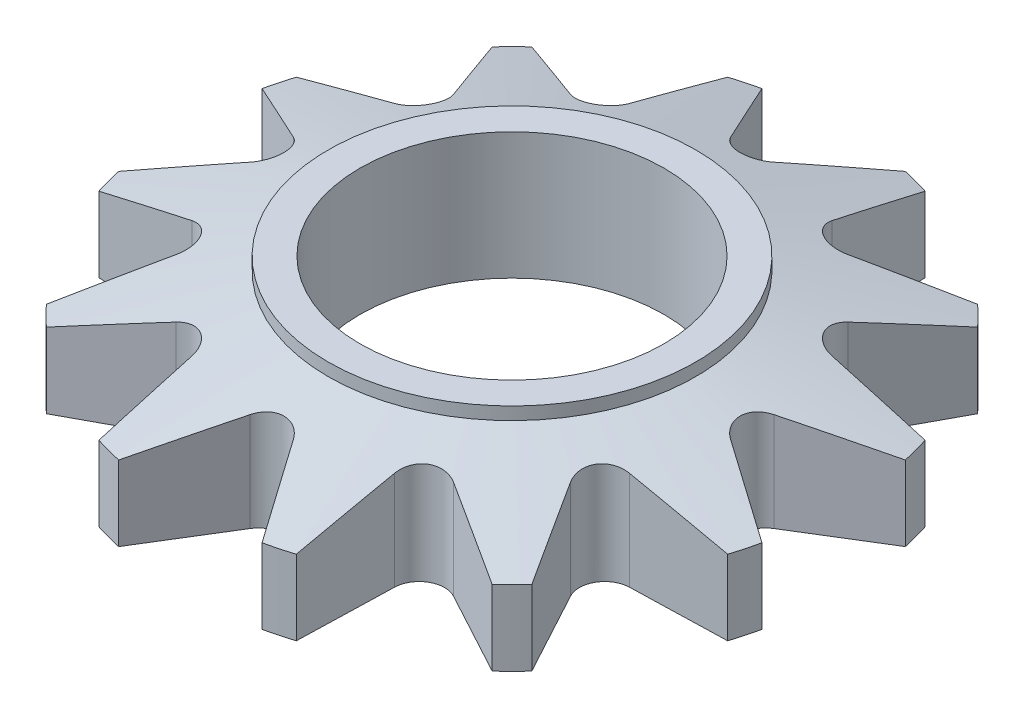
from build123d import *

# Parameters (mm, degrees)
SKETCH1_R               = 260
SKETCH1_R_2             = 120
BOSS_EXTRUDE1_DEPTH     = 45
SKETCH2_R               = 145
SKETCH2_R_2             = 120
BOSS_EXTRUDE3_DEPTH     = 55
CUT_EXTRUDE1_DEPTH      = 56
CUT_EXTRUDE1_DEPTH_BACK = 46
SCALE2_SCALE            = 0.4


with BuildPart() as part:
    # Sketch1 → Boss-Extrude1 (new body, symmetric)
    with BuildSketch(Plane(origin=(0, 0, 0), x_dir=(1, 0, 0), z_dir=(0, 1, 0))):
        Circle(SKETCH1_R)
        Circle(SKETCH1_R_2, mode=Mode.SUBTRACT)
    extrude(amount=BOSS_EXTRUDE1_DEPTH, both=True)

    # Sketch2 → Boss-Extrude3 (add)
    with BuildSketch(Plane(origin=(0, 0, 0), x_dir=(1, 0, 0), z_dir=(0, 1, 0))):
        Circle(SKETCH2_R)
        Circle(SKETCH2_R_2, mode=Mode.SUBTRACT)
    extrude(amount=BOSS_EXTRUDE3_DEPTH)

    # Sketch4 → Cut-Extrude1 (cut, two sides)
    with BuildSketch(Plane(origin=(0, 0, 0), x_dir=(1, 0, 0), z_dir=(0, 1, 0))) as cut_extrude1_sk:
        with BuildLine():
            Line((-17.033179487, 189.518072861), (-56.573051576, 253.770545642))
            ThreePointArc((-56.573051576, 253.770545642), (0, 260), (56.573051576, 253.770545642))
            Line((56.573051576, 253.770545642), (17.033179487, 189.518072861))
            ThreePointArc((17.033179487, 189.518072861), (0, 180), (-17.033179487, 189.518072861))
        make_face()
        with BuildLine():
            Line((109.510202574, 155.61087583), (175.878972656, 191.48521347))
            ThreePointArc((175.878972656, 191.48521347), (130, 225.166604984), (77.891572987, 248.058265046))
            Line((77.891572987, 248.058265046), (80.007870288, 172.644055317))
            ThreePointArc((80.007870288, 172.644055317), (90, 155.884572681), (109.510202574, 155.61087583))
        make_face()
        with BuildLine():
            Line((172.644055318, 80.007870287), (248.058265047, 77.891572986))
            ThreePointArc((248.058265047, 77.891572986), (225.166604985, 130), (191.485213471, 175.878972655))
            Line((191.485213471, 175.878972655), (155.610875831, 109.510202573))
            ThreePointArc((155.610875831, 109.510202573), (155.884572682, 90), (172.644055318, 80.007870287))
        make_face()
        with BuildLine():
            Line((189.518072862, -17.033179488), (253.770545643, -56.573051577))
            ThreePointArc((253.770545643, -56.573051577), (260.000000001, -1e-09), (253.770545643, 56.573051575))
            Line((253.770545643, 56.573051575), (189.518072862, 17.033179486))
            ThreePointArc((189.518072862, 17.033179486), (180.000000001, -1e-09), (189.518072862, -17.033179488))
        make_face()
        with BuildLine():
            Line((155.610875831, -109.510202575), (191.485213471, -175.878972657))
            ThreePointArc((191.485213471, -175.878972657), (225.166604985, -130.000000001), (248.058265047, -77.891572988))
            Line((248.058265047, -77.891572988), (172.644055318, -80.007870289))
            ThreePointArc((172.644055318, -80.007870289), (155.884572682, -90.000000001), (155.610875831, -109.510202575))
        make_face()
        with BuildLine():
            Line((80.007870288, -172.644055319), (77.891572987, -248.058265048))
            ThreePointArc((77.891572987, -248.058265048), (130, -225.166604986), (175.878972656, -191.485213472))
            Line((175.878972656, -191.485213472), (109.510202574, -155.610875832))
            ThreePointArc((109.510202574, -155.610875832), (90, -155.884572683), (80.007870288, -172.644055319))
        make_face()
        with BuildLine():
            Line((-17.033179487, -189.518072863), (-56.573051576, -253.770545644))
            ThreePointArc((-56.573051576, -253.770545644), (0, -260.000000002), (56.573051576, -253.770545644))
            Line((56.573051576, -253.770545644), (17.033179487, -189.518072863))
            ThreePointArc((17.033179487, -189.518072863), (0, -180.000000002), (-17.033179487, -189.518072863))
        make_face()
        with BuildLine():
            Line((-109.510202574, -155.610875832), (-175.878972656, -191.485213472))
            ThreePointArc((-175.878972656, -191.485213472), (-130, -225.166604986), (-77.891572987, -248.058265048))
            Line((-77.891572987, -248.058265048), (-80.007870288, -172.644055319))
            ThreePointArc((-80.007870288, -172.644055319), (-90, -155.884572683), (-109.510202574, -155.610875832))
        make_face()
        with BuildLine():
            Line((-172.644055318, -80.007870289), (-248.058265047, -77.891572988))
            ThreePointArc((-248.058265047, -77.891572988), (-225.166604985, -130.000000001), (-191.485213471, -175.878972657))
            Line((-191.485213471, -175.878972657), (-155.610875831, -109.510202575))
            ThreePointArc((-155.610875831, -109.510202575), (-155.884572682, -90.000000001), (-172.644055318, -80.007870289))
        make_face()
        with BuildLine():
            Line((-189.518072862, 17.033179486), (-253.770545643, 56.573051575))
            ThreePointArc((-253.770545643, 56.573051575), (-260.000000001, -1e-09), (-253.770545643, -56.573051577))
            Line((-253.770545643, -56.573051577), (-189.518072862, -17.033179488))
            ThreePointArc((-189.518072862, -17.033179488), (-180.000000001, -1e-09), (-189.518072862, 17.033179486))
        make_face()
        with BuildLine():
            Line((-155.610875831, 109.510202573), (-191.485213471, 175.878972655))
            ThreePointArc((-191.485213471, 175.878972655), (-225.166604985, 130), (-248.058265047, 77.891572986))
            Line((-248.058265047, 77.891572986), (-172.644055318, 80.007870287))
            ThreePointArc((-172.644055318, 80.007870287), (-155.884572682, 90), (-155.610875831, 109.510202573))
        make_face()
        with BuildLine():
            Line((-80.007870288, 172.644055317), (-77.891572987, 248.058265046))
            ThreePointArc((-77.891572987, 248.058265046), (-130, 225.166604984), (-175.878972656, 191.48521347))
            Line((-175.878972656, 191.48521347), (-109.510202574, 155.61087583))
            ThreePointArc((-109.510202574, 155.61087583), (-90, 155.884572681), (-80.007870288, 172.644055317))
        make_face()
    extrude(amount=CUT_EXTRUDE1_DEPTH, mode=Mode.SUBTRACT)
    extrude(cut_extrude1_sk.sketch, amount=-CUT_EXTRUDE1_DEPTH_BACK, mode=Mode.SUBTRACT)

    # Sketch9 → Cut-Revolve2 (revolve, cut)
    with BuildSketch(Plane(origin=(0, 0, 0), x_dir=(0, 0, -1), z_dir=(1, 0, 0))):
        Polygon((145, 45), (312.942286341, 45), (312.942286341, 0), align=None)
    revolve(axis=Axis((0, 0, 0), (0, 1, 0)), mode=Mode.SUBTRACT)


with BuildPart() as part_1:
    # Scale2: scaled about (-4.97e-06, -3.05192852, -9e-09)
    add(part.part.scale(SCALE2_SCALE).moved(Location((-2.982e-06, -1.831157112, -5e-09))))


solid = part_1.part
